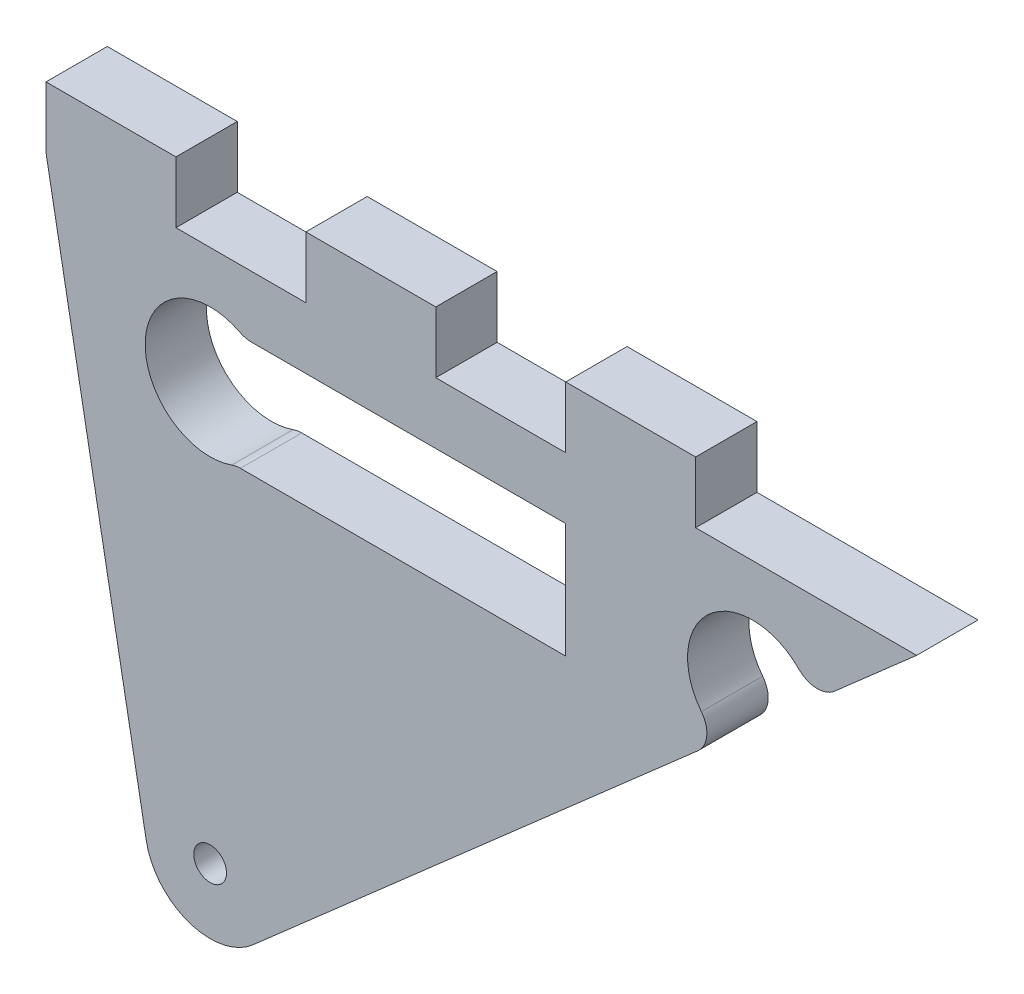
from build123d import *

# Parameters (mm, degrees)
SKETCH1_R           = 1.6
BOSS_EXTRUDE1_DEPTH = 5.9944


with BuildPart() as part:
    # Sketch1 → Boss-Extrude1 (new body)
    with BuildSketch(Plane.XY):
        with BuildLine():
            Line((316.995622149, 78.216780382), (326.749772708, 25.13420903))
            ThreePointArc((326.749772708, 25.13420903), (330.912307442, 20.282357802), (337.186376688, 21.508412799))
            Line((337.186376688, 21.508412799), (380.686318009, 59.686636906))
            ThreePointArc((380.686318009, 59.686636906), (381.539726589, 61.358310991), (381.012274461, 63.159586846))
            ThreePointArc((381.012274461, 63.159586846), (381.827165591, 71.841961695), (390.541875435, 71.52335081))
            ThreePointArc((390.541875435, 71.52335081), (392.259481176, 70.76662697), (394.027759373, 71.395906456))
            Line((394.027759373, 71.395906456), (402.058752504, 78.4444))
            Line((402.058752504, 78.4444), (380.453796067, 78.4444))
            Line((380.453796067, 78.4444), (380.453796067, 84.4388))
            Line((380.453796067, 84.4388), (367.753796067, 84.4388))
            Line((367.753796067, 84.4388), (367.753796067, 78.4444))
            Line((367.753796067, 78.4444), (355.053796067, 78.4444))
            Line((355.053796067, 78.4444), (355.053796067, 84.4388))
            Line((355.053796067, 84.4388), (342.353796067, 84.4388))
            Line((342.353796067, 84.4388), (342.353796067, 78.4444))
            Line((342.353796067, 78.4444), (329.653796067, 78.4444))
            Line((329.653796067, 78.4444), (329.653796067, 84.4388))
            Line((329.653796067, 84.4388), (316.953796067, 84.4388))
            Line((316.953796067, 84.4388), (316.953796067, 78.675830573))
            ThreePointArc((316.953796067, 78.675830573), (316.9642742, 78.445354708), (316.995622149, 78.216780382))
        make_face()
        with Locations((332.996689228, 26.282106781)):
            Circle(SKETCH1_R, mode=Mode.SUBTRACT)
        with BuildLine():
            Line((339.346689286, 72.45), (337.033543957, 72.45))
            ThreePointArc((337.033543957, 72.45), (336.440455672, 72.520213312), (335.880156908, 72.726971429))
            ThreePointArc((335.880156908, 72.726971429), (326.660420383, 67.486768409), (335.113137596, 61.08248539))
            ThreePointArc((335.113137596, 61.08248539), (335.530243547, 61.19114772), (335.95971692, 61.227719546))
            Line((335.95971692, 61.227719546), (339.346689286, 61.227719546))
            Line((339.346689286, 61.227719546), (367.753796067, 61.227719546))
            Line((367.753796067, 61.227719546), (367.753796067, 72.45))
            Line((367.753796067, 72.45), (339.346689286, 72.45))
        make_face(mode=Mode.SUBTRACT)
    extrude(amount=BOSS_EXTRUDE1_DEPTH)


solid = part.part
